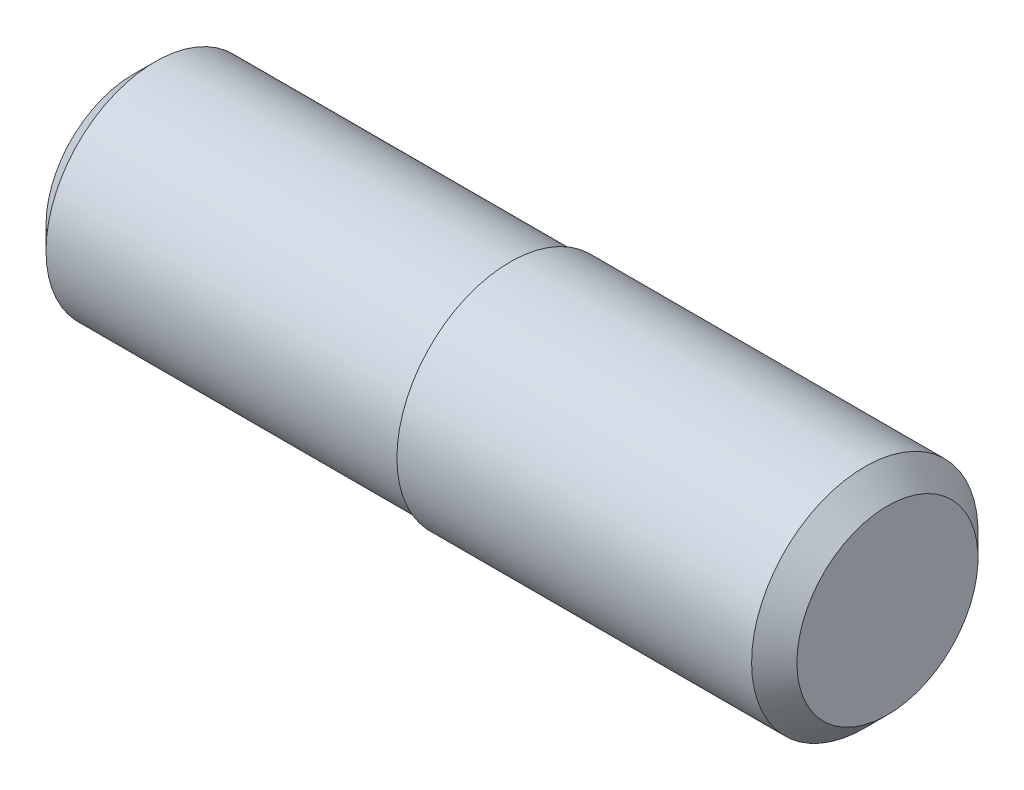
from build123d import *

# Parameters (mm, degrees)
CHAMFER1_SIZE = 0.3


with BuildPart() as part:
    # Sketch1 → Revolve1 (revolve)
    with BuildSketch(Plane.XY):
        Polygon((-6.79253012, 1.45), (-1.79253012, 1.45), (-1.79253012, 1.5), (3.20746988, 1.5), (3.20746988, 0), (-6.79253012, 0), align=None)
    revolve(axis=Axis((-2.508674699, 0, 0), (1, 0, 0)))

    # Chamfer1
    chamfer1_edges = [part.edges().sort_by_distance(p)[0] for p in [
        (3.20746988, -1.5, 0),
        (-6.79253012, -1.45, 0),
    ]]
    chamfer(chamfer1_edges, length=CHAMFER1_SIZE)


solid = part.part
